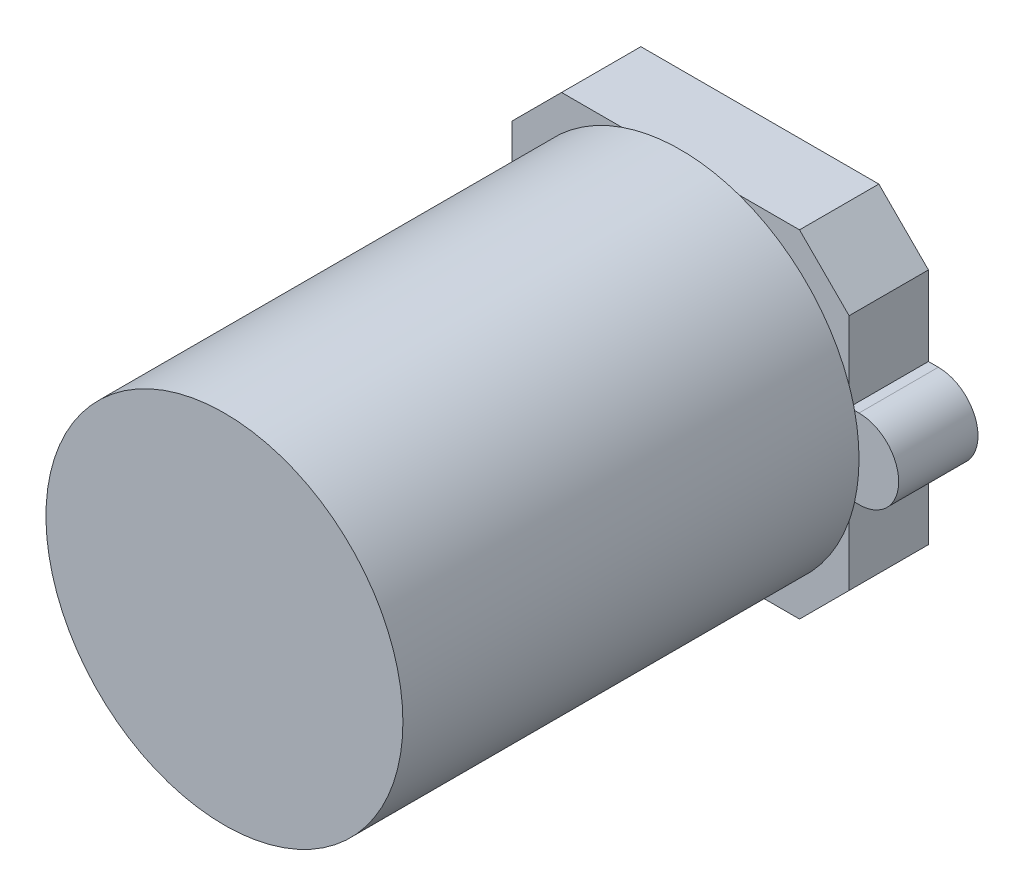
from build123d import *

# Parameters (mm, degrees)
SKETCH1_W           = 17
SKETCH1_H           = 17
BOSS_EXTRUDE1_DEPTH = 4
CHAMFER1_SIZE       = 2.5
BOSS_EXTRUDE3_DEPTH = 4
SKETCH2_R           = 9
BOSS_EXTRUDE2_DEPTH = 23


with BuildPart() as part:
    # Sketch1 → Boss-Extrude1 (new body)
    with BuildSketch(Plane.XY):
        Rectangle(SKETCH1_W, SKETCH1_H)
    extrude(amount=BOSS_EXTRUDE1_DEPTH)

    # Chamfer1
    chamfer1_edges = [part.edges().sort_by_distance(p)[0] for p in [
        (8.5, -8.5, 2),
        (-8.5, -8.5, 2),
        (-8.5, 8.5, 2),
        (8.5, 8.5, 2),
    ]]
    chamfer(chamfer1_edges, length=CHAMFER1_SIZE)

    # Sketch3 → Boss-Extrude3 (add)
    with BuildSketch(Plane.XY):
        with BuildLine():
            Line((-8.5, 2), (-9, 2))
            ThreePointArc((-9, 2), (-11, 0), (-9, -2))
            Line((-9, -2), (-8.5, -2))
            Line((-8.5, -2), (-8.5, 2))
        make_face()
    boss_extrude3 = extrude(amount=BOSS_EXTRUDE3_DEPTH)

    # Mirror1: Boss-Extrude3 across plane
    add(boss_extrude3.mirror(Plane(origin=(0, 0, 0), x_dir=(0, 0, 1), z_dir=(1, 0, 0))))

    # Sketch2 → Boss-Extrude2 (add)
    with BuildSketch(Plane.XY.offset(4)):
        Circle(SKETCH2_R)
    extrude(amount=BOSS_EXTRUDE2_DEPTH)


solid = part.part
